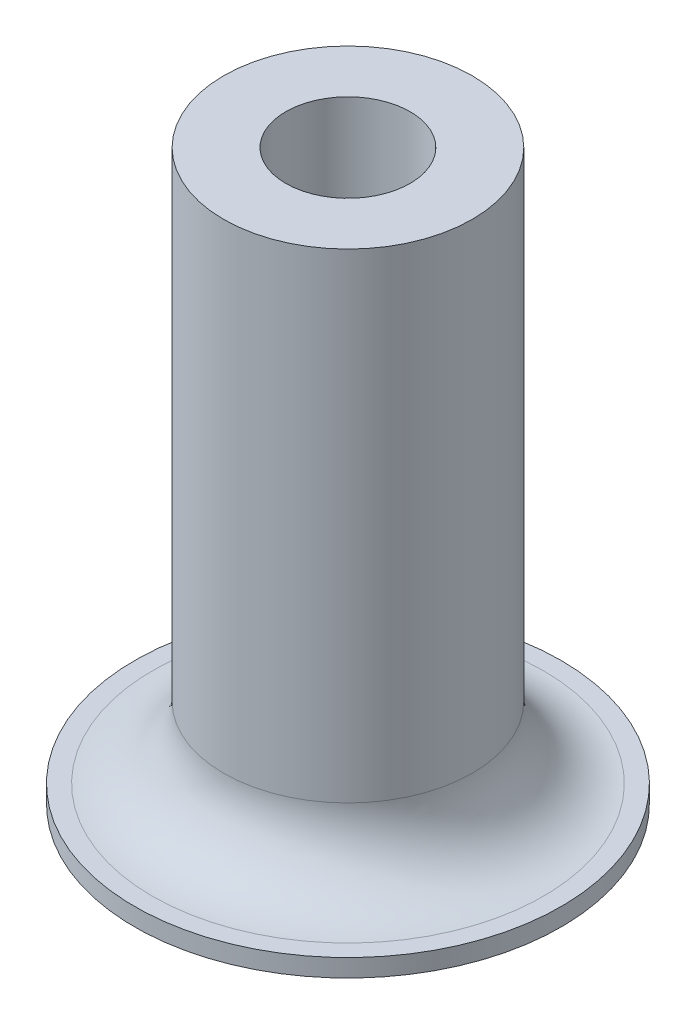
from build123d import *

# Parameters (mm, degrees)
CROQUIS1_R              = 7
CROQUIS1_R_2            = 3.5
SALIENTE_EXTRUIR1_DEPTH = 32
CROQUIS2_R              = 12
CROQUIS2_R_2            = 7
SALIENTE_EXTRUIR2_DEPTH = 1
REDONDEO1_R             = 4


with BuildPart() as part:
    # Croquis1 → Saliente-Extruir1 (new body)
    with BuildSketch(Plane(origin=(0, 0, 0), x_dir=(1, 0, 0), z_dir=(0, 1, 0))):
        Circle(CROQUIS1_R)
        Circle(CROQUIS1_R_2, mode=Mode.SUBTRACT)
    extrude(amount=SALIENTE_EXTRUIR1_DEPTH)

    # Croquis2 → Saliente-Extruir2 (add)
    with BuildSketch(Plane.XZ):
        Circle(CROQUIS2_R)
        Circle(CROQUIS2_R_2, mode=Mode.SUBTRACT)
    extrude(amount=-SALIENTE_EXTRUIR2_DEPTH)

    # Redondeo1
    redondeo1_edges = [part.edges().sort_by_distance(p)[0] for p in [
        (-7, 1, 0),
    ]]
    fillet(redondeo1_edges, radius=REDONDEO1_R)


solid = part.part
